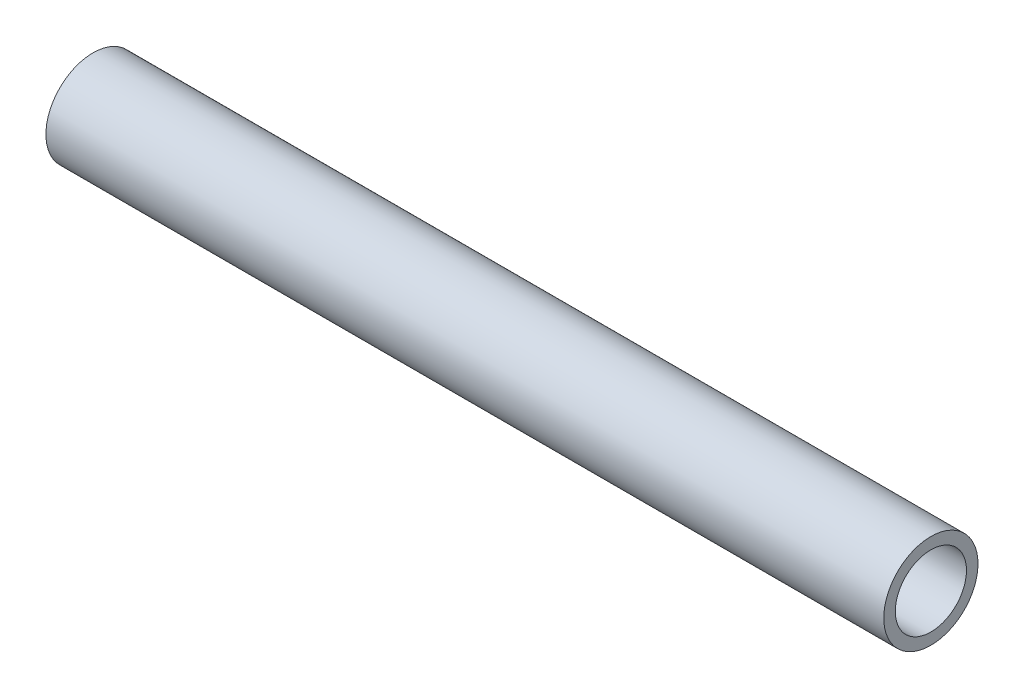
from build123d import *

# Parameters (mm, degrees)
SKETCH1_R           = 28.575
SKETCH1_R_2         = 21.59
BOSS_EXTRUDE1_DEPTH = 254


with BuildPart() as part:
    # Sketch1 → Boss-Extrude1 (new body, symmetric)
    with BuildSketch(Plane(origin=(0, 0, 0), x_dir=(0, 0, -1), z_dir=(1, 0, 0))):
        Circle(SKETCH1_R)
        Circle(SKETCH1_R_2, mode=Mode.SUBTRACT)
    extrude(amount=BOSS_EXTRUDE1_DEPTH, both=True)


solid = part.part
